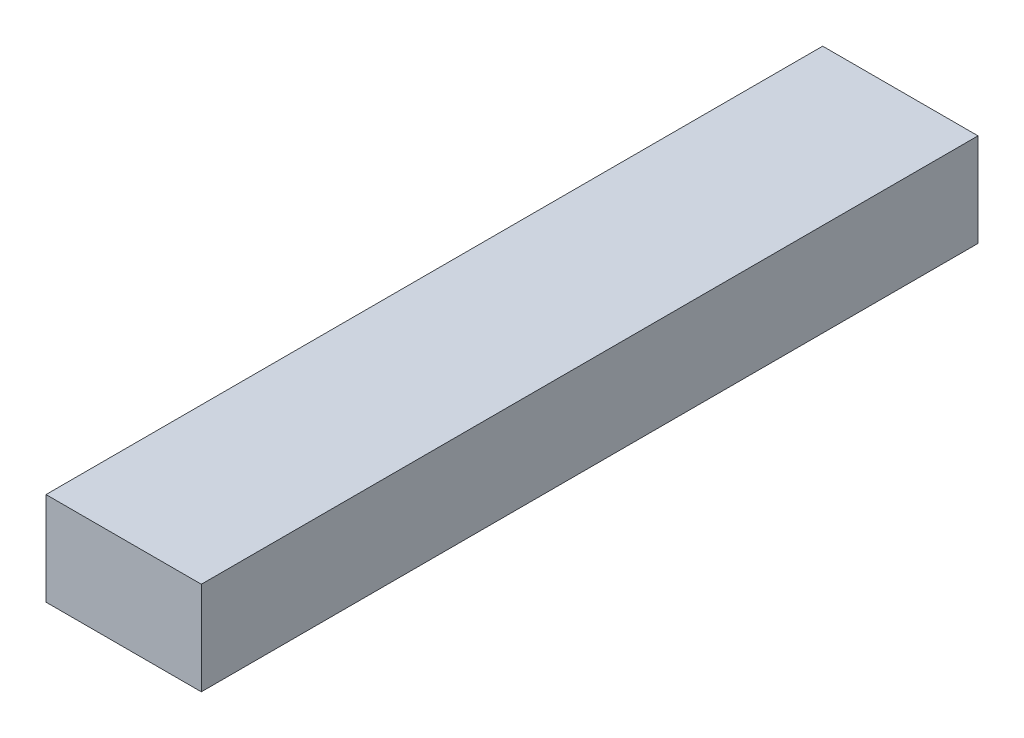
from build123d import *

# Parameters (mm, degrees)
SKETCH1_W           = 1
SKETCH1_H           = 5
BOSS_EXTRUDE1_DEPTH = 0.3


with BuildPart() as part:
    # Sketch1 → Boss-Extrude1 (new body, symmetric)
    with BuildSketch(Plane(origin=(0, 0, 0), x_dir=(1, 0, 0), z_dir=(0, 1, 0))):
        Rectangle(SKETCH1_W, SKETCH1_H)
    extrude(amount=BOSS_EXTRUDE1_DEPTH, both=True)


solid = part.part
